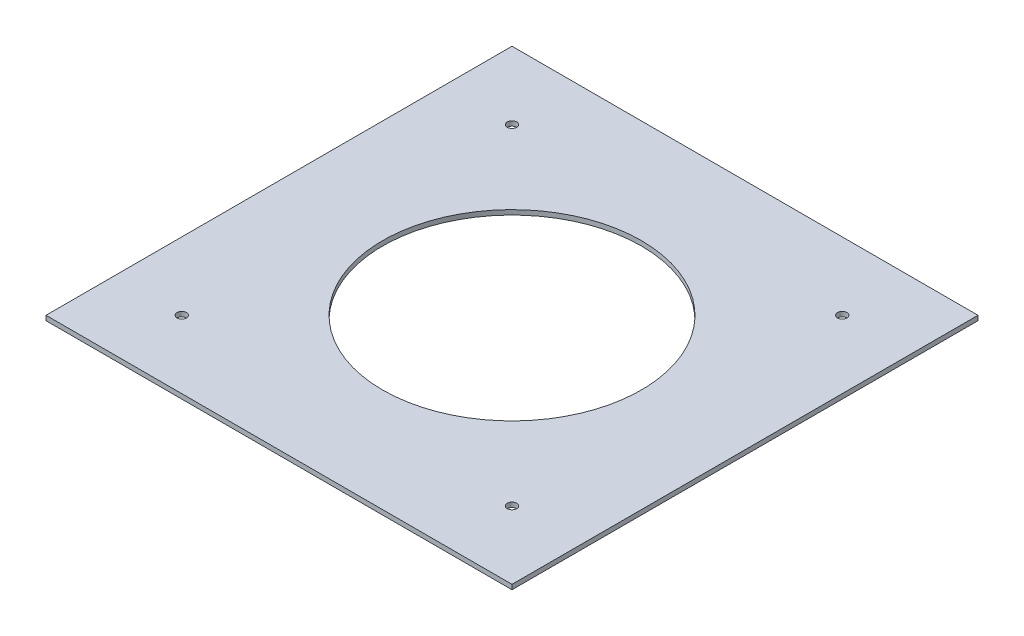
from build123d import *

# Parameters (mm, degrees)
SKETCH1_W           = 98.782817332
SKETCH1_H           = 98.782817332
BOSS_EXTRUDE1_DEPTH = 1.000000032
SKETCH3_R           = 0.999998
CUT_EXTRUDE2_DEPTH  = 2.000000032
SKETCH8_R           = 27.432
CUT_EXTRUDE9_DEPTH  = 2.000000032


with BuildPart() as part:
    # Sketch1 → Boss-Extrude1 (new body)
    with BuildSketch(Plane(origin=(0, 0, 0), x_dir=(1, 0, 0), z_dir=(0, 1, 0))):
        Rectangle(SKETCH1_W, SKETCH1_H)
    extrude(amount=BOSS_EXTRUDE1_DEPTH)

    # Sketch3 → Cut-Extrude2 (cut, through all)
    with BuildSketch(Plane(origin=(0, 0, 0), x_dir=(1, 0, 0), z_dir=(0, 1, 0))):
        with Locations((35.001787507, 35.001787507)):
            Circle(SKETCH3_R)
        with Locations((35.001787507, -35.001787507)):
            Circle(SKETCH3_R)
        with Locations((-35.001787507, -35.001787507)):
            Circle(SKETCH3_R)
        with Locations((-35.001787507, 35.001787507)):
            Circle(SKETCH3_R)
    extrude(amount=CUT_EXTRUDE2_DEPTH, mode=Mode.SUBTRACT)

    # Sketch8 → Cut-Extrude9 (cut, through all)
    with BuildSketch(Plane(origin=(0, 0, 0), x_dir=(1, 0, 0), z_dir=(0, 1, 0))):
        Circle(SKETCH8_R)
    extrude(amount=CUT_EXTRUDE9_DEPTH, mode=Mode.SUBTRACT)


solid = part.part
